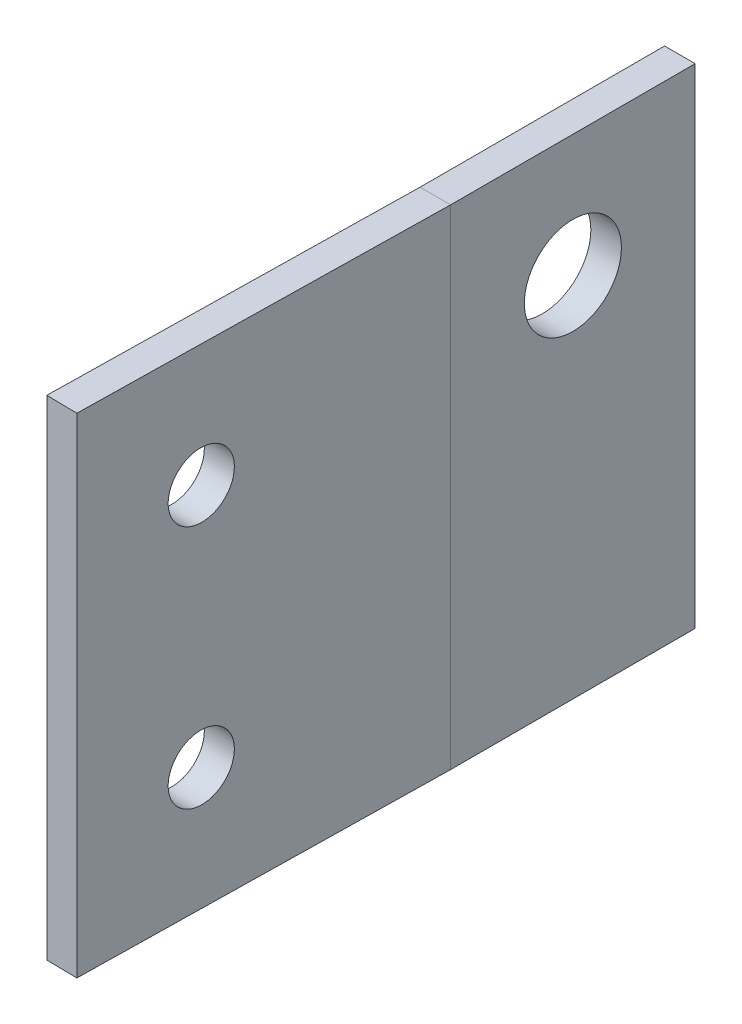
from build123d import *

# Parameters (mm, degrees)
SKETCH1_W                        = 25.4
SKETCH1_H                        = 50.8
BOSS_EXTRUDE1_DEPTH              = 3.175
F_3_8_CLEARANCE_HOLE1_D          = 10.0838
BOSS_EXTRUDE2_DEPTH              = 50.8
SKETCH5_W                        = 3.3782
SKETCH5_H                        = 3.839835412
F_1_4_CLEARANCE_HOLE1_AT_2_COUNT = 2
F_1_4_CLEARANCE_HOLE1_AT_2_PITCH = 25.4


with BuildPart() as part:
    # Sketch1 → Boss-Extrude1 (new body)
    with BuildSketch(Plane(origin=(0, 0, 0), x_dir=(0, 0, -1), z_dir=(1, 0, 0))):
        with Locations((0, -12.7)):
            Rectangle(SKETCH1_W, SKETCH1_H)
    extrude(amount=BOSS_EXTRUDE1_DEPTH)

    # 3/8 Clearance Hole1 (through all)
    with Locations(Plane(origin=(3.175, 0, 0), x_dir=(0, 0, -1), z_dir=(1, 0, 0))):
        with Locations((0, 0)):
            Hole(F_3_8_CLEARANCE_HOLE1_D / 2)


with BuildPart() as body_2:
    # Sketch6 → Boss-Extrude2 (new body)
    with BuildSketch(Plane(origin=(0, 12.7, 0), x_dir=(1, 0, 0), z_dir=(0, 1, 0))):
        Polygon((0, -12.7), (-0.664936685, -50.794197185), (2.509579747, -50.849608576), (3.175, -12.727707805), (3.175, -12.7), align=None)
    extrude(amount=-BOSS_EXTRUDE2_DEPTH)

    # Sketch5 → 1/4 Clearance Hole1 (revolve, cut)
    with BuildSketch(Plane(origin=(2.731225309, 0, 38.151542847), x_dir=(0.017452406, 0, -0.999847695), z_dir=(0, 1, 0))):
        with Locations((1.6891, 1.919917706)):
            Rectangle(SKETCH5_W, SKETCH5_H)
    f_1_4_clearance_hole1 = revolve(axis=Axis((9.080258173, 0, 38.262365628), (-0.999847695, 0, -0.017452406)), mode=Mode.SUBTRACT)

    # 1/4 Clearance Hole1 at 2: 1/4 Clearance Hole1 ×2
    with Locations(*[(0, -i * F_1_4_CLEARANCE_HOLE1_AT_2_PITCH, 0) for i in range(1, F_1_4_CLEARANCE_HOLE1_AT_2_COUNT)]):
        add(f_1_4_clearance_hole1, mode=Mode.SUBTRACT)


solid = Compound([part.part, body_2.part])
